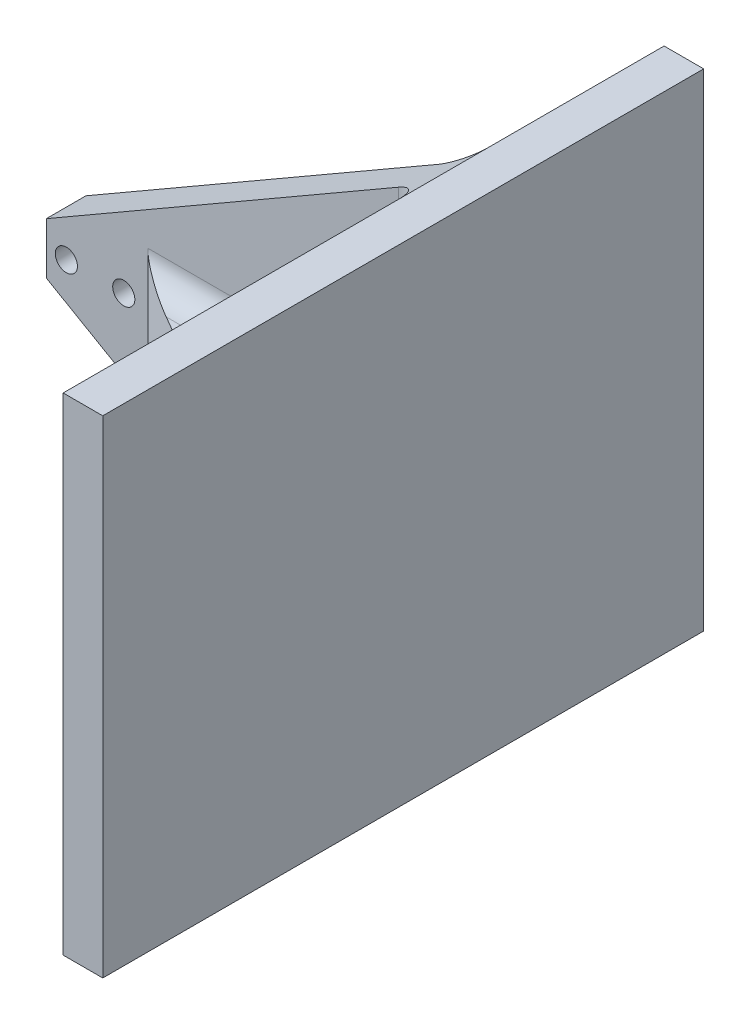
from build123d import *

# Parameters (mm, degrees)
BOSS_EXTRUDE1_DEPTH = 10
BOSS_EXTRUDE2_DEPTH = 13
SKETCH4_W           = 151.79281634
SKETCH4_H           = 122.98522628
BOSS_EXTRUDE3_DEPTH = 10
SKETCH5_R           = 2.8
CUT_EXTRUDE1_DEPTH  = 101.99281634
FILLET1_R           = 6.35


with BuildPart() as part:
    # Sketch1 → Boss-Extrude1 (new body)
    with BuildSketch(Plane.XY):
        Polygon((-24.634, 0), (-24.634, 13), (70.616, 67.99261314), (70.616, -54.99261314), align=None)
    extrude(amount=BOSS_EXTRUDE1_DEPTH)

    # Sketch3 → Boss-Extrude2 (add)
    with BuildSketch(Plane(origin=(0, 13, 0), x_dir=(1, 0, 0), z_dir=(0, 1, 0))):
        Polygon((70.616, -50.19281634), (70.616, -10), (1, -10), align=None)
    extrude(amount=-BOSS_EXTRUDE2_DEPTH)

    # Sketch4 → Boss-Extrude3 (add)
    with BuildSketch(Plane(origin=(70.616, 0, 0), x_dir=(0, 0, -1), z_dir=(1, 0, 0))):
        with Locations((-25.09640817, 6.5)):
            Rectangle(SKETCH4_W, SKETCH4_H)
    extrude(amount=BOSS_EXTRUDE3_DEPTH)

    # Sketch5 → Cut-Extrude1 (cut, through all)
    with BuildSketch(Plane(origin=(0, 0, 0), x_dir=(-1, 0, 0), z_dir=(0, 0, -1))):
        with Locations((5.067, 6.5)):
            Circle(SKETCH5_R)
        with Locations((19.567, 6.5)):
            Circle(SKETCH5_R)
    extrude(amount=-CUT_EXTRUDE1_DEPTH, mode=Mode.SUBTRACT)

    # Fillet1
    fillet1_edges = [part.edges().sort_by_distance(p)[0] for p in [
        (70.616, 40.49630657, 10),
        (70.616, 6.5, 50.19281634),
        (35.808, 13, 10),
        (70.616, 13, 30.09640817),
        (35.808, 0, 10),
        (70.616, 0, 30.09640817),
        (70.616, -27.49630657, 10),
        (70.616, 6.5, 0),
    ]]
    fillet(fillet1_edges, radius=FILLET1_R)


solid = part.part
